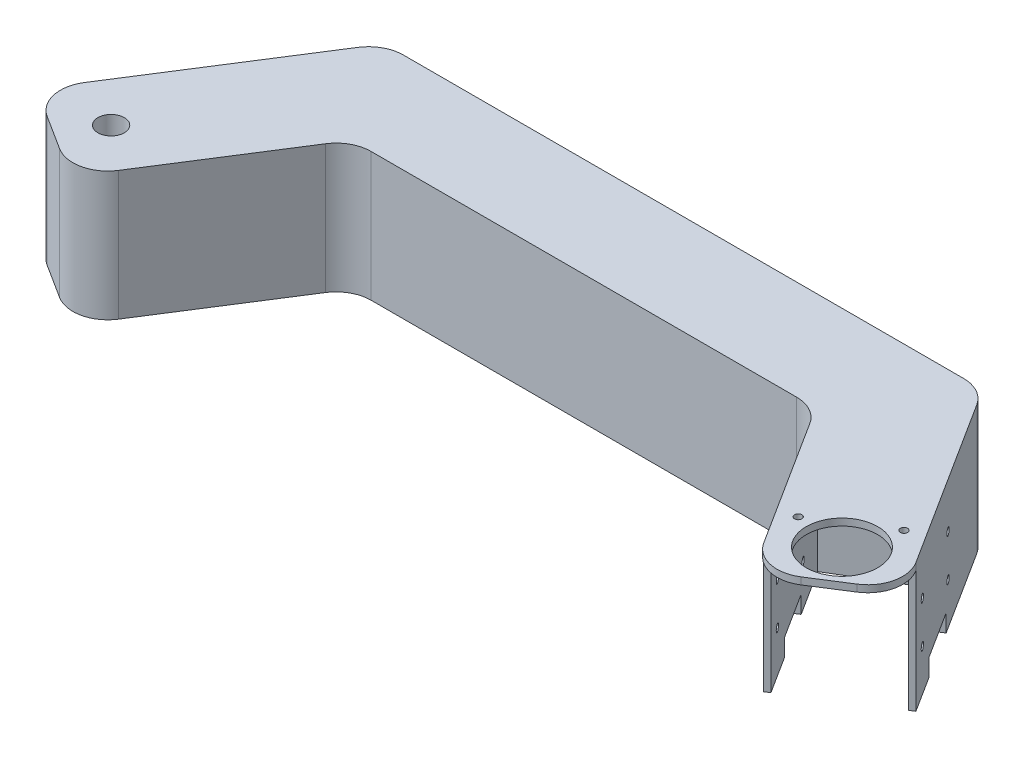
from build123d import *

# Parameters (mm, degrees)
BOSS_EXTRUDE1_DEPTH = 37
SKETCH3_R           = 10.25
SKETCH3_R_2         = 1.05
SKETCH3_R_3         = 3.79119947
CUT_EXTRUDE1_DEPTH  = 38
CUT_EXTRUDE5_DEPTH  = 35
SKETCH10_R          = 1.05
CUT_EXTRUDE6_DEPTH  = 35
SKETCH15_W          = 15.770937014
SKETCH15_H          = 5.000421699
CUT_EXTRUDE8_DEPTH  = 35
SKETCH17_W          = 10.43544962
SKETCH17_H          = 35
CUT_EXTRUDE10_DEPTH = 38


with BuildPart() as part:
    # Sketch1 → Boss-Extrude1 (new body)
    with BuildSketch(Plane(origin=(0, 0, 0), x_dir=(1, 0, 0), z_dir=(0, 1, 0))):
        with BuildLine():
            Line((30.91362152, -11.506988518), (61.410209359, 36.471719739))
            ThreePointArc((61.410209359, 36.471719739), (65.035248289, 39.872184028), (69.84963689, 41.10738726))
            Line((69.84963689, 41.10738726), (230.684249594, 41.10738726))
            ThreePointArc((230.684249594, 41.10738726), (235.498638195, 39.872184028), (239.123677125, 36.471719739))
            Line((239.123677125, 36.471719739), (269.620264964, -11.506988518))
            ThreePointArc((269.620264964, -11.506988518), (270.941569742, -19.045741561), (266.545169913, -25.310748528))
            Line((266.545169913, -25.310748528), (256.707586966, -31.563787081))
            ThreePointArc((256.707586966, -31.563787081), (249.168833923, -32.885091859), (242.903826956, -28.488692029))
            Line((242.903826956, -28.488692029), (219.802518103, 7.855405338))
            ThreePointArc((219.802518103, 7.855405338), (216.177479173, 11.255869627), (211.363090572, 12.491072858))
            Line((211.363090572, 12.491072858), (89.170795912, 12.491072858))
            ThreePointArc((89.170795912, 12.491072858), (84.356407311, 11.255869627), (80.731368381, 7.855405338))
            Line((80.731368381, 7.855405338), (57.630059528, -28.488692029))
            ThreePointArc((57.630059528, -28.488692029), (51.365052561, -32.885091859), (43.826299518, -31.563787081))
            Line((43.826299518, -31.563787081), (33.988716571, -25.310748528))
            ThreePointArc((33.988716571, -25.310748528), (29.592316741, -19.045741561), (30.91362152, -11.506988518))
        make_face()
    extrude(amount=BOSS_EXTRUDE1_DEPTH)

    # Sketch3 → Cut-Extrude1 (cut, through all)
    with BuildSketch(Plane(origin=(0, 37, 0), x_dir=(1, 0, 0), z_dir=(0, 1, 0))):
        with Locations((255.189179464, -18.309954767)):
            Circle(SKETCH3_R)
        with Locations((259.912867141, -5.235675639)):
            Circle(SKETCH3_R_2)
        with Locations((241.346126573, -17.037207093)):
            Circle(SKETCH3_R_2)
        with Locations((45.34470702, -18.309954767)):
            Circle(SKETCH3_R_3)
    extrude(amount=-CUT_EXTRUDE1_DEPTH, mode=Mode.SUBTRACT)

    # Sketch9 → Cut-Extrude5 (cut)
    with BuildSketch(Plane.XZ):
        Polygon((220.770453038, -9.128850504), (250.101424494, 37.016053635), (274.286034243, 21.643649867), (245.369620358, -23.849052233), align=None)
    extrude(amount=-CUT_EXTRUDE5_DEPTH, mode=Mode.SUBTRACT)

    # Sketch10 → Cut-Extrude6 (cut)
    with BuildSketch(Plane(origin=(186.824736014, 0, -118.750945563), x_dir=(-0.536433248, 0, -0.843942753), z_dir=(0.843942753, 0, -0.536433248))):
        with Locations((-148.344514011, 24)):
            Circle(SKETCH10_R)
        with Locations((-148.344514011, 12)):
            Circle(SKETCH10_R)
        with Locations((-124.344514011, 12)):
            Circle(SKETCH10_R)
        with Locations((-124.344514011, 24)):
            Circle(SKETCH10_R)
    extrude(amount=-CUT_EXTRUDE6_DEPTH, mode=Mode.SUBTRACT)

    # Sketch15 → Cut-Extrude8 (cut)
    with BuildSketch(Plane(origin=(160.108298005, 0, -101.769242052), x_dir=(0.536433248, 0, 0.843942753), z_dir=(-0.843942753, 0, 0.536433248))):
        with Locations((134.025974507, 2.50021085)):
            Rectangle(SKETCH15_W, SKETCH15_H)
    extrude(amount=-CUT_EXTRUDE8_DEPTH, mode=Mode.SUBTRACT)

    # Sketch17 → Cut-Extrude10 (cut)
    with BuildSketch(Plane(origin=(160.108298005, 0, -101.769242052), x_dir=(0.536433248, 0, 0.843942753), z_dir=(-0.843942753, 0, 0.536433248))):
        with Locations((159.562238821, 17.5)):
            Rectangle(SKETCH17_W, SKETCH17_H)
    extrude(amount=-CUT_EXTRUDE10_DEPTH, mode=Mode.SUBTRACT)


solid = part.part
